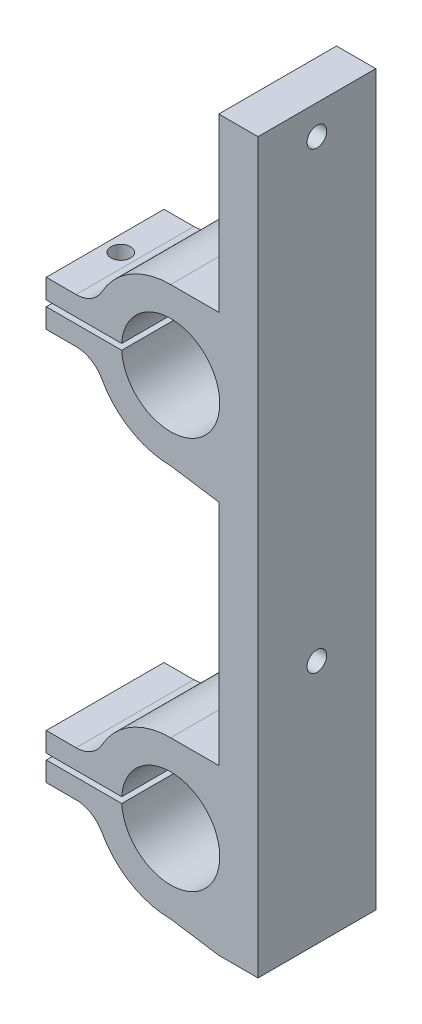
from build123d import *

# Parameters (mm, degrees)
EXTRUDE_1_DEPTH     = 12
SKETCH_2_R          = 1
CUT_EXTRUDE_1_DEPTH = 4
SKETCH_3_R          = 1
CUT_EXTRUDE_2_DEPTH = 10


with BuildPart() as part:
    # 草图1 → 凸台-拉伸1 (new body)
    with BuildSketch(Plane.XY):
        with BuildLine():
            Line((0, 8), (4.9, 8))
            Line((4.9, 8), (4.9, 25.5))
            Line((4.9, 25.5), (8.9, 25.5))
            Line((8.9, 25.5), (8.9, -48.754024521))
            Line((8.9, -48.754024521), (4.9, -48.754024521))
            Line((4.9, -48.754024521), (0, -48))
            ThreePointArc((0, -48), (-4.07207787, -46.886086103), (-7.010169708, -43.854545455))
            ThreePointArc((-7.010169708, -43.854545455), (-8.111954148, -42.717717711), (-9.638983349, -42.3))
            Line((-9.638983349, -42.3), (-12.681165581, -42.3))
            Line((-12.681165581, -42.3), (-12.681165581, -40.3))
            Line((-12.681165581, -40.3), (-4.990991885, -40.3))
            ThreePointArc((-4.990991885, -40.3), (5, -40), (-4.990991885, -39.7))
            Line((-4.990991885, -39.7), (-12.681165581, -39.7))
            Line((-12.681165581, -39.7), (-12.681165581, -37.7))
            Line((-12.681165581, -37.7), (-9.638983349, -37.7))
            ThreePointArc((-9.638983349, -37.7), (-8.111954148, -37.282282289), (-7.010169708, -36.145454545))
            ThreePointArc((-7.010169708, -36.145454545), (-4.07207787, -33.113913897), (0, -32))
            Line((0, -32), (4.9, -32))
            Line((4.9, -32), (4.9, -31))
            Line((4.9, -31), (4.9, -8.754024521))
            Line((4.9, -8.754024521), (0, -8))
            ThreePointArc((0, -8), (-4.07207787, -6.886086103), (-7.010169708, -3.854545455))
            ThreePointArc((-7.010169708, -3.854545455), (-8.111954148, -2.717717711), (-9.638983349, -2.3))
            Line((-9.638983349, -2.3), (-12.681165581, -2.3))
            Line((-12.681165581, -2.3), (-12.681165581, -0.3))
            Line((-12.681165581, -0.3), (-4.990991885, -0.3))
            ThreePointArc((-4.990991885, -0.3), (5, 0), (-4.990991885, 0.3))
            Line((-4.990991885, 0.3), (-12.681165581, 0.3))
            Line((-12.681165581, 0.3), (-12.681165581, 2.3))
            Line((-12.681165581, 2.3), (-9.638983349, 2.3))
            ThreePointArc((-9.638983349, 2.3), (-8.111954148, 2.717717711), (-7.010169708, 3.854545455))
            ThreePointArc((-7.010169708, 3.854545455), (-4.07207787, 6.886086103), (0, 8))
        make_face()
    extrude(amount=EXTRUDE_1_DEPTH)

    # 草图2 → 切除-拉伸1 (cut)
    with BuildSketch(Plane.ZY.offset(-4.9)):
        with Locations((6, 22.5)):
            Circle(SKETCH_2_R)
        with Locations((6, -23.78)):
            Circle(SKETCH_2_R)
    extrude(amount=-CUT_EXTRUDE_1_DEPTH, mode=Mode.SUBTRACT)

    # 草图3 → 切除-拉伸2 (cut)
    with BuildSketch(Plane(origin=(0, 2.3, 0), x_dir=(1, 0, 0), z_dir=(0, 1, 0))):
        with Locations((-11.081165581, -6)):
            Circle(SKETCH_3_R)
    extrude(amount=-CUT_EXTRUDE_2_DEPTH, mode=Mode.SUBTRACT)


solid = part.part
